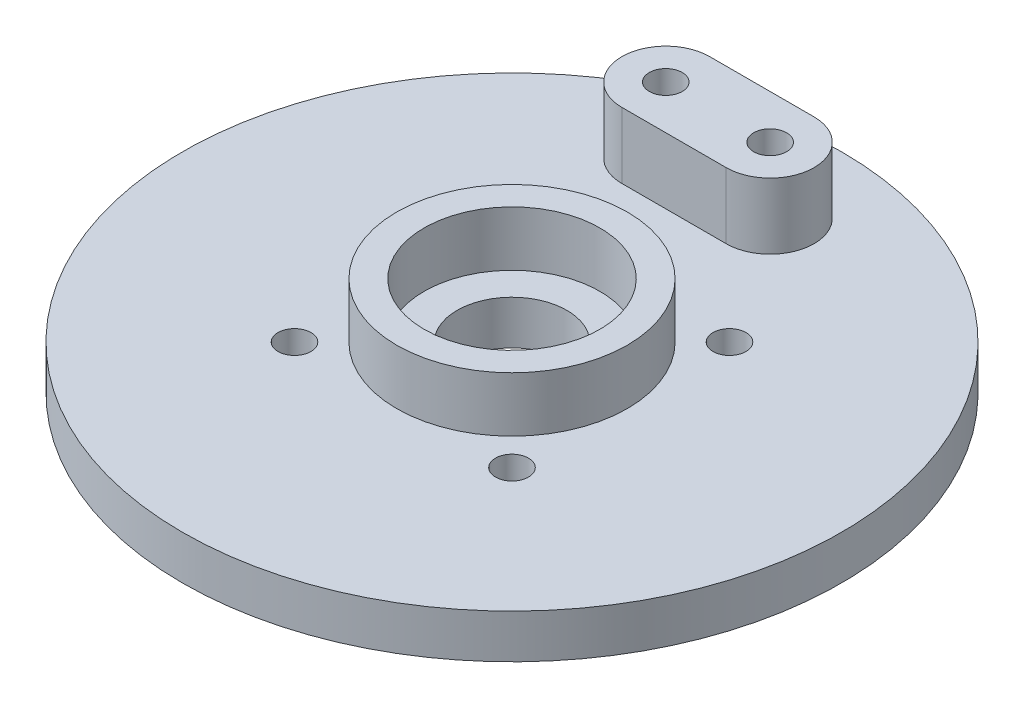
from build123d import *

# Parameters (mm, degrees)
SKETCH1_R           = 30
SKETCH1_R_2         = 5
BOSS_EXTRUDE1_DEPTH = 4
SKETCH4_R           = 10.5
SKETCH4_R_2         = 8
BOSS_EXTRUDE2_DEPTH = 5
SKETCH6_R           = 1.5
CUT_EXTRUDE3_DEPTH  = 5
SKETCH7_R           = 1.5
BOSS_EXTRUDE3_DEPTH = 6
SKETCH8_R           = 1.5
CUT_EXTRUDE4_DEPTH  = 5


with BuildPart() as part:
    # Sketch1 → Boss-Extrude1 (new body)
    with BuildSketch(Plane(origin=(0, 0, 0), x_dir=(1, 0, 0), z_dir=(0, 1, 0))):
        Circle(SKETCH1_R)
        Circle(SKETCH1_R_2, mode=Mode.SUBTRACT)
    extrude(amount=BOSS_EXTRUDE1_DEPTH)

    # Sketch4 → Boss-Extrude2 (add)
    with BuildSketch(Plane(origin=(0, 4, 0), x_dir=(1, 0, 0), z_dir=(0, 1, 0))):
        Circle(SKETCH4_R)
        Circle(SKETCH4_R_2, mode=Mode.SUBTRACT)
    extrude(amount=BOSS_EXTRUDE2_DEPTH)

    # Sketch6 → Cut-Extrude3 (cut, through all)
    with BuildSketch(Plane(origin=(0, 4, 0), x_dir=(1, 0, 0), z_dir=(0, 1, 0))):
        with Locations((-7.5, 21.5)):
            Circle(SKETCH6_R)
        with Locations((2, 21.5)):
            Circle(SKETCH6_R)
    extrude(amount=-CUT_EXTRUDE3_DEPTH, mode=Mode.SUBTRACT)

    # Sketch7 → Boss-Extrude3 (add)
    with BuildSketch(Plane(origin=(0, 4, 0), x_dir=(1, 0, 0), z_dir=(0, 1, 0))):
        with BuildLine():
            Line((2, 25.5), (-7.5, 25.5))
            ThreePointArc((-7.5, 25.5), (-11.5, 21.5), (-7.5, 17.5))
            Line((-7.5, 17.5), (2, 17.5))
            ThreePointArc((2, 17.5), (6, 21.5), (2, 25.5))
        make_face()
        with Locations((-7.5, 21.5)):
            Circle(SKETCH7_R, mode=Mode.SUBTRACT)
        with Locations((2, 21.5)):
            Circle(SKETCH7_R, mode=Mode.SUBTRACT)
    extrude(amount=BOSS_EXTRUDE3_DEPTH)

    # Sketch8 → Cut-Extrude4 (cut, through all)
    with BuildSketch(Plane(origin=(0, 4, 0), x_dir=(1, 0, 0), z_dir=(0, 1, 0))):
        with Locations((-9.899494937, 9.899494937)):
            Circle(SKETCH8_R)
        with Locations((9.899494937, 9.899494937)):
            Circle(SKETCH8_R)
        with Locations((9.899494937, -9.899494937)):
            Circle(SKETCH8_R)
        with Locations((-9.899494937, -9.899494937)):
            Circle(SKETCH8_R)
    extrude(amount=-CUT_EXTRUDE4_DEPTH, mode=Mode.SUBTRACT)


solid = part.part
